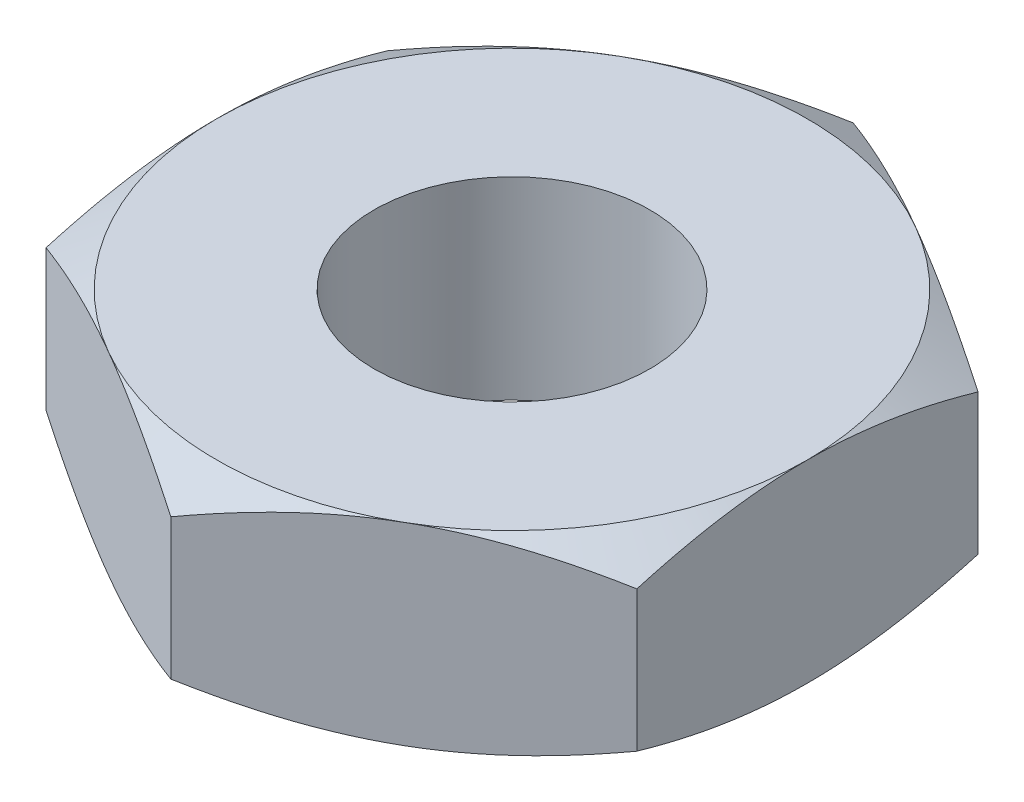
from build123d import *

# Parameters (mm, degrees)
EXTRUDE_1_DEPTH     = 1.8
SKETCH_4_R          = 1.2835
CUT_EXTRUDE_1_DEPTH = 2.8


with BuildPart() as part:
    # 草图1 → 凸台-拉伸1 (new body)
    with BuildSketch(Plane(origin=(0, 0, 0), x_dir=(1, 0, 0), z_dir=(0, 1, 0))):
        Polygon((0, 3.175426481), (-2.75, 1.58771324), (-2.75, -1.58771324), (0, -3.175426481), (2.75, -1.58771324), (2.75, 1.58771324), align=None)
    extrude(amount=EXTRUDE_1_DEPTH)

    # 草图4 → 切除-拉伸1 (cut, through all)
    with BuildSketch(Plane(origin=(0, 1.8, 0), x_dir=(1, 0, 0), z_dir=(0, 1, 0))):
        Circle(SKETCH_4_R)
    extrude(amount=-CUT_EXTRUDE_1_DEPTH, mode=Mode.SUBTRACT)

    # 草图2 → 切除-旋转1 (revolve, cut)
    with BuildSketch(Plane(origin=(0, 0, 0), x_dir=(0, 0, -1), z_dir=(1, 0, 0))):
        Polygon((3.175426481, 1.8), (3.175426481, 1.554379907), (2.75, 1.8), align=None)
    revolve(axis=Axis((0, 0, 0), (0, 1, 0)), mode=Mode.SUBTRACT)

    # 草图3 → 切除-旋转2 (revolve, cut)
    with BuildSketch(Plane(origin=(0, 0, 0), x_dir=(0, 0, -1), z_dir=(1, 0, 0))):
        Polygon((3.175426481, 0), (3.175426481, 0.245620093), (2.75, 0), align=None)
    revolve(axis=Axis((0, 0, 0), (0, 1, 0)), mode=Mode.SUBTRACT)


solid = part.part
